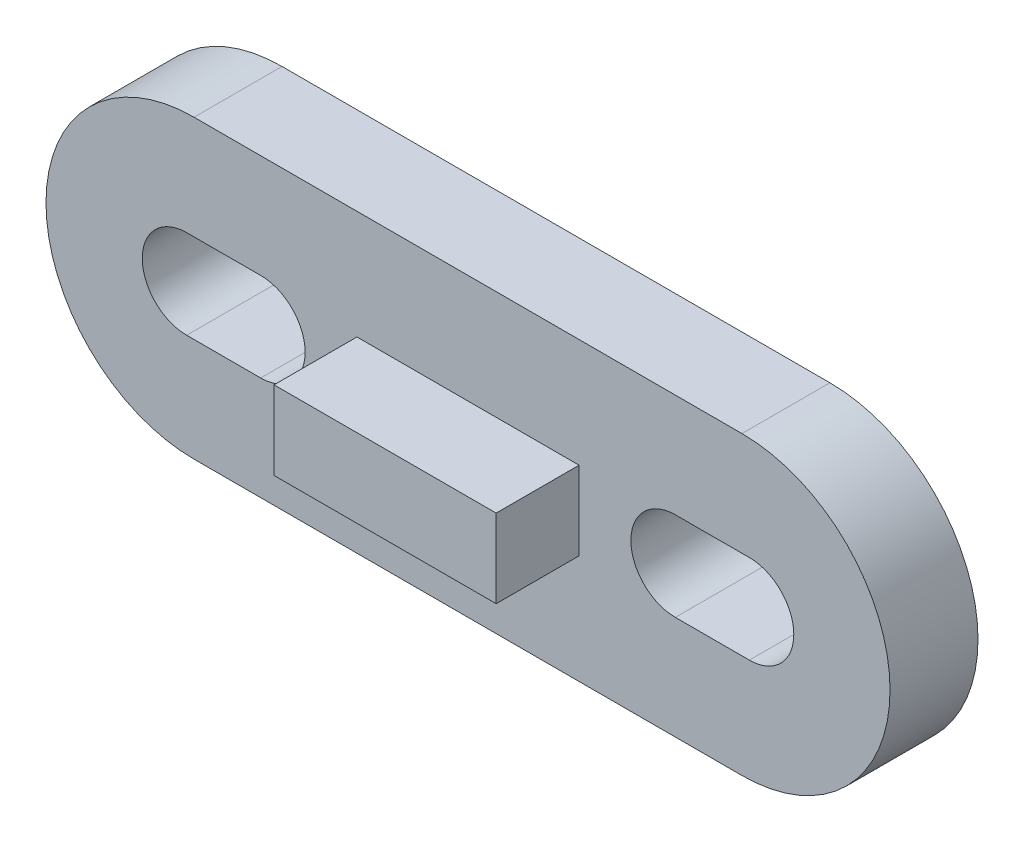
from build123d import *

# Parameters (mm, degrees)
BOSS_EXTRUDE2_DEPTH = 2.97
SKETCH5_W           = 7.5
SKETCH5_H           = 2.65
BOSS_EXTRUDE3_DEPTH = 2.8


with BuildPart() as part:
    # Sketch3 → Boss-Extrude2 (new body)
    with BuildSketch(Plane.XY):
        with BuildLine():
            Line((-9.25, 5), (9.25, 5))
            ThreePointArc((9.25, 5), (14.25, 0), (9.25, -5))
            Line((9.25, -5), (-9.25, -5))
            ThreePointArc((-9.25, -5), (-14.25, 0), (-9.25, 5))
        make_face()
        with BuildLine():
            Line((-9.5, 1.5), (-7, 1.5))
            ThreePointArc((-7, 1.5), (-5.5, 0), (-7, -1.5))
            Line((-7, -1.5), (-9.5, -1.5))
            ThreePointArc((-9.5, -1.5), (-11, 0), (-9.5, 1.5))
        make_face(mode=Mode.SUBTRACT)
        with BuildLine():
            Line((9.5, -1.5), (7, -1.5))
            ThreePointArc((7, -1.5), (5.5, 0), (7, 1.5))
            Line((7, 1.5), (9.5, 1.5))
            ThreePointArc((9.5, 1.5), (11, 0), (9.5, -1.5))
        make_face(mode=Mode.SUBTRACT)
    extrude(amount=BOSS_EXTRUDE2_DEPTH)

    # Sketch5 → Boss-Extrude3 (add)
    with BuildSketch(Plane.XY.offset(2.97)):
        Rectangle(SKETCH5_W, SKETCH5_H)
    extrude(amount=BOSS_EXTRUDE3_DEPTH)


solid = part.part
